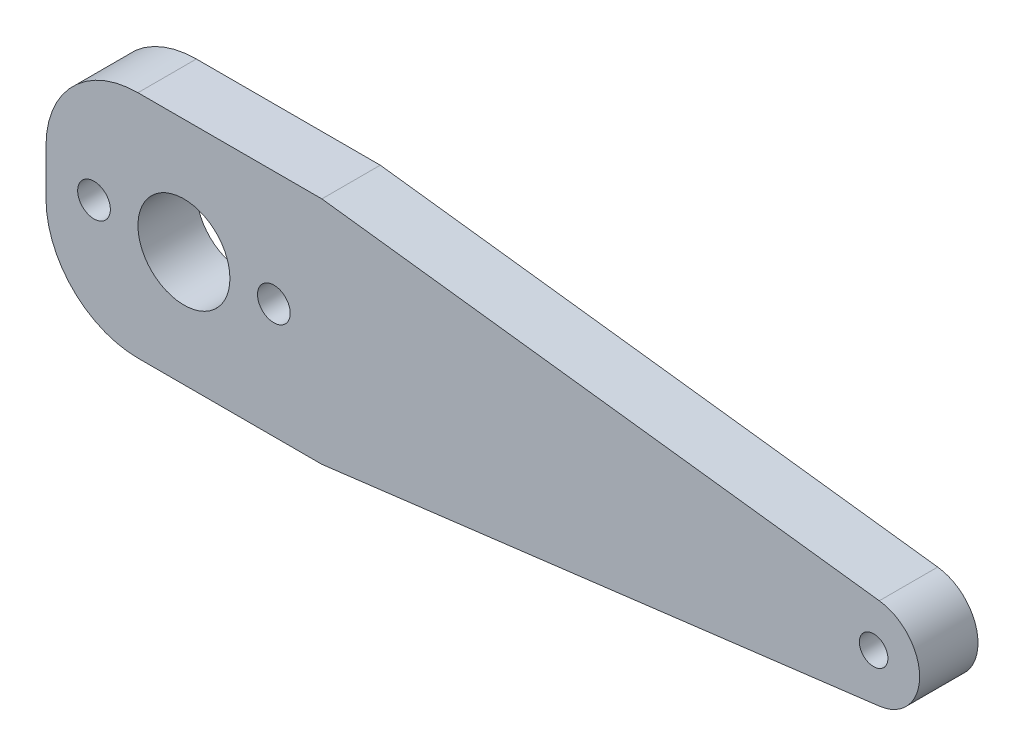
from build123d import *

# Parameters (mm, degrees)
SKETCH1_R           = 1.778
SKETCH1_R_2         = 1.55
SKETCH1_R_3         = 5
BOSS_EXTRUDE1_DEPTH = 6.35
FILLET1_R           = 10


with BuildPart() as part:
    # Sketch1 → Boss-Extrude1 (new body)
    with BuildSketch(Plane.XY):
        with BuildLine():
            Line((90.617041925, 17.461725961), (30, 25))
            Line((30, 25), (0, 25))
            Line((0, 25), (0, 0))
            Line((0, 0), (30, 0))
            Line((30, 0), (90.617033237, 7.538165184))
            ThreePointArc((90.617033237, 7.538165184), (95, 12.499941736), (90.617041925, 17.461725961))
        make_face()
        with Locations((24.779, 12.499946113)):
            Circle(SKETCH1_R, mode=Mode.SUBTRACT)
        with Locations((5.221, 12.499946113)):
            Circle(SKETCH1_R, mode=Mode.SUBTRACT)
        with Locations((90, 12.499946113)):
            Circle(SKETCH1_R_2, mode=Mode.SUBTRACT)
        with Locations((15, 12.499946113)):
            Circle(SKETCH1_R_3, mode=Mode.SUBTRACT)
    extrude(amount=BOSS_EXTRUDE1_DEPTH)

    # Fillet1
    fillet1_edges = [part.edges().sort_by_distance(p)[0] for p in [
        (0, 0, 3.175),
        (0, 25, 3.175),
    ]]
    fillet(fillet1_edges, radius=FILLET1_R)


solid = part.part
